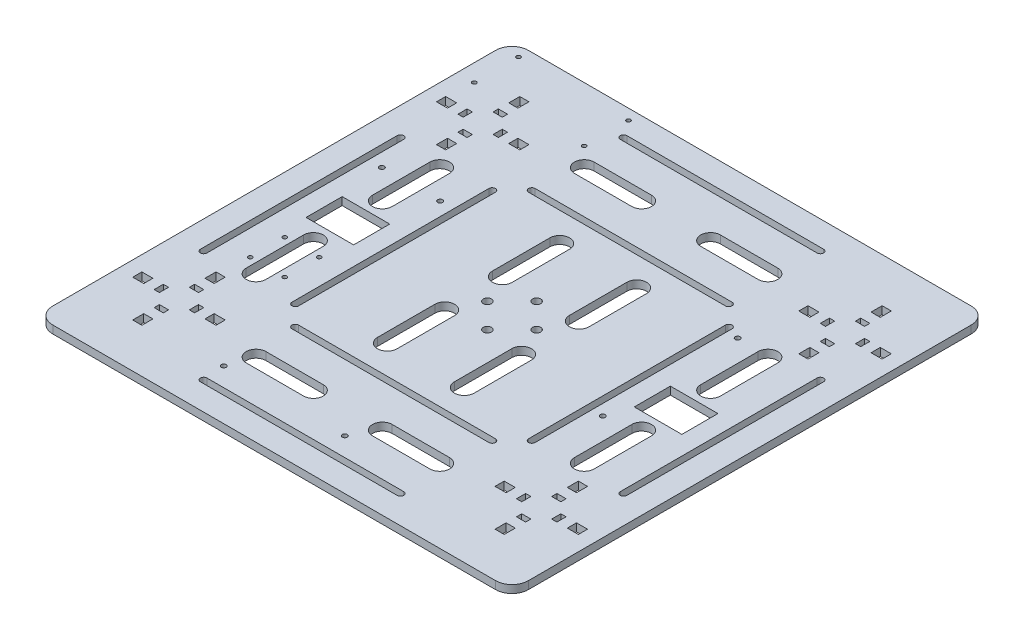
from build123d import *

# Parameters (mm, degrees)
SKETCH1_W                 = 290
SKETCH1_H                 = 290
BOSS_EXTRUDE1_DEPTH       = 4.7625
FILLET1_R                 = 10
SKETCH3_W                 = 5.588
SKETCH3_H                 = 6.731
SKETCH3_W_2               = 6.731
SKETCH3_H_2               = 5.588
SKETCH3_H_3               = 3.2
SKETCH3_W_3               = 3.2
CUT_EXTRUDE1_DEPTH        = 4.7625
MIRROR2_COPY_1_SKETCH_W   = 5.588
MIRROR2_COPY_1_SKETCH_H   = 6.731
MIRROR2_COPY_1_SKETCH_W_2 = 6.731
MIRROR2_COPY_1_SKETCH_H_2 = 5.588
MIRROR2_COPY_1_SKETCH_H_3 = 3.2
MIRROR2_COPY_1_SKETCH_W_3 = 3.2
MIRROR2_COPY_1_DEPTH      = 4.7625
CUT_EXTRUDE2_DEPTH        = 4.7625
SKETCH5_W                 = 29
SKETCH5_H                 = 22
CUT_EXTRUDE3_DEPTH        = 4.7625
CUT_EXTRUDE4_DEPTH        = 4.7625
SKETCH7_R                 = 2.5
CUT_EXTRUDE5_DEPTH        = 4.7625
SKETCH10_R                = 1.25
SKETCH10_R_2              = 1.5
CUT_EXTRUDE6_DEPTH        = 4.7625


with BuildPart() as part:
    # Sketch1 → Boss-Extrude1 (new body)
    with BuildSketch(Plane(origin=(0, 0, 0), x_dir=(1, 0, 0), z_dir=(0, 1, 0))):
        Rectangle(SKETCH1_W, SKETCH1_H)
    extrude(amount=BOSS_EXTRUDE1_DEPTH)

    # Fillet1
    fillet1_edges = [part.edges().sort_by_distance(p)[0] for p in [
        (-145, 2.38125, -145),
        (145, 2.38125, -145),
        (145, 2.38125, 145),
        (-145, 2.38125, 145),
    ]]
    fillet(fillet1_edges, radius=FILLET1_R)

    # Sketch3 → Cut-Extrude1 (cut)
    with BuildSketch(Plane(origin=(0, 4.7625, 0), x_dir=(1, 0, 0), z_dir=(0, 1, 0))):
        with Locations((-110.456, 114.6345)):
            Rectangle(SKETCH3_W, SKETCH3_H)
        with Locations((-88.4215, 92.6)):
            Rectangle(SKETCH3_W_2, SKETCH3_H_2)
        with Locations((-110.456, 70.5655)):
            Rectangle(SKETCH3_W, SKETCH3_H)
        with Locations((-132.4905, 92.6)):
            Rectangle(SKETCH3_W_2, SKETCH3_H_2)
        with Locations((-110.456, 103.325)):
            Rectangle(SKETCH3_W, SKETCH3_H_3)
        with Locations((-121.181, 92.6)):
            Rectangle(SKETCH3_W_3, SKETCH3_H_2)
        with Locations((-99.731, 92.6)):
            Rectangle(SKETCH3_W_3, SKETCH3_H_2)
        with Locations((-110.456, 81.875)):
            Rectangle(SKETCH3_W, SKETCH3_H_3)
    cut_extrude1 = extrude(amount=-CUT_EXTRUDE1_DEPTH, mode=Mode.SUBTRACT)

    # Mirror1: Cut-Extrude1 across plane
    add(cut_extrude1.mirror(Plane.XY), mode=Mode.SUBTRACT)

    # Mirror2: Cut-Extrude1 across plane
    add(cut_extrude1.mirror(Plane(origin=(0, 0, 0), x_dir=(0, 0, 1), z_dir=(1, 0, 0))), mode=Mode.SUBTRACT)

    # Mirror2 copy 1 sketch → Mirror2 copy 1 (cut)
    with BuildSketch(Plane(origin=(0, 4.7625, 0), x_dir=(-1, 0, 0), z_dir=(0, 1, 0))):
        with Locations((-110.456, 114.6345)):
            Rectangle(MIRROR2_COPY_1_SKETCH_W, MIRROR2_COPY_1_SKETCH_H)
        with Locations((-88.4215, 92.6)):
            Rectangle(MIRROR2_COPY_1_SKETCH_W_2, MIRROR2_COPY_1_SKETCH_H_2)
        with Locations((-110.456, 70.5655)):
            Rectangle(MIRROR2_COPY_1_SKETCH_W, MIRROR2_COPY_1_SKETCH_H)
        with Locations((-132.4905, 92.6)):
            Rectangle(MIRROR2_COPY_1_SKETCH_W_2, MIRROR2_COPY_1_SKETCH_H_2)
        with Locations((-110.456, 103.325)):
            Rectangle(MIRROR2_COPY_1_SKETCH_W, MIRROR2_COPY_1_SKETCH_H_3)
        with Locations((-121.181, 92.6)):
            Rectangle(MIRROR2_COPY_1_SKETCH_W_3, MIRROR2_COPY_1_SKETCH_H_2)
        with Locations((-99.731, 92.6)):
            Rectangle(MIRROR2_COPY_1_SKETCH_W_3, MIRROR2_COPY_1_SKETCH_H_2)
        with Locations((-110.456, 81.875)):
            Rectangle(MIRROR2_COPY_1_SKETCH_W, MIRROR2_COPY_1_SKETCH_H_3)
    extrude(amount=-MIRROR2_COPY_1_DEPTH, mode=Mode.SUBTRACT)

    # Sketch4 → Cut-Extrude2 (cut)
    with BuildSketch(Plane(origin=(0, 4.7625, 0), x_dir=(1, 0, 0), z_dir=(0, 1, 0))):
        with BuildLine():
            Line((-60, 130), (60, 130))
            ThreePointArc((60, 130), (62, 128), (60, 126))
            Line((60, 126), (-60, 126))
            ThreePointArc((-60, 126), (-62, 128), (-60, 130))
        make_face()
        with BuildLine():
            Line((-60, 74.12), (60, 74.12))
            ThreePointArc((60, 74.12), (62, 72.12), (60, 70.12))
            Line((60, 70.12), (-60, 70.12))
            ThreePointArc((-60, 70.12), (-62, 72.12), (-60, 74.12))
        make_face()
        with BuildLine():
            Line((130, 60), (130, -60))
            ThreePointArc((130, -60), (128, -62), (126, -60))
            Line((126, -60), (126, 60))
            ThreePointArc((126, 60), (128, 62), (130, 60))
        make_face()
        with BuildLine():
            Line((74.12, 60), (74.12, -60))
            ThreePointArc((74.12, -60), (72.12, -62), (70.12, -60))
            Line((70.12, -60), (70.12, 60))
            ThreePointArc((70.12, 60), (72.12, 62), (74.12, 60))
        make_face()
        with BuildLine():
            Line((60, -130), (-60, -130))
            ThreePointArc((-60, -130), (-62, -128), (-60, -126))
            Line((-60, -126), (60, -126))
            ThreePointArc((60, -126), (62, -128), (60, -130))
        make_face()
        with BuildLine():
            Line((60, -74.12), (-60, -74.12))
            ThreePointArc((-60, -74.12), (-62, -72.12), (-60, -70.12))
            Line((-60, -70.12), (60, -70.12))
            ThreePointArc((60, -70.12), (62, -72.12), (60, -74.12))
        make_face()
        with BuildLine():
            Line((-130, -60), (-130, 60))
            ThreePointArc((-130, 60), (-128, 62), (-126, 60))
            Line((-126, 60), (-126, -60))
            ThreePointArc((-126, -60), (-128, -62), (-130, -60))
        make_face()
        with BuildLine():
            Line((-74.12, -60), (-74.12, 60))
            ThreePointArc((-74.12, 60), (-72.12, 62), (-70.12, 60))
            Line((-70.12, 60), (-70.12, -60))
            ThreePointArc((-70.12, -60), (-72.12, -62), (-74.12, -60))
        make_face()
    extrude(amount=-CUT_EXTRUDE2_DEPTH, mode=Mode.SUBTRACT)

    # Sketch5 → Cut-Extrude3 (cut)
    with BuildSketch(Plane(origin=(0, 4.7625, 0), x_dir=(1, 0, 0), z_dir=(0, 1, 0))):
        with Locations((-100.06, 0)):
            Rectangle(SKETCH5_W, SKETCH5_H)
        with Locations((100.06, 0)):
            Rectangle(SKETCH5_W, SKETCH5_H)
    extrude(amount=-CUT_EXTRUDE3_DEPTH, mode=Mode.SUBTRACT)

    # Sketch6 → Cut-Extrude4 (cut)
    with BuildSketch(Plane(origin=(0, 4.7625, 0), x_dir=(1, 0, 0), z_dir=(0, 1, 0))):
        with BuildLine():
            Line((-56, 106.06), (-21, 106.06))
            ThreePointArc((-21, 106.06), (-15, 100.06), (-21, 94.06))
            Line((-21, 94.06), (-56, 94.06))
            ThreePointArc((-56, 94.06), (-62, 100.06), (-56, 106.06))
        make_face()
        with BuildLine():
            Line((21, 106.06), (56, 106.06))
            ThreePointArc((56, 106.06), (62, 100.06), (56, 94.06))
            Line((56, 94.06), (21, 94.06))
            ThreePointArc((21, 94.06), (15, 100.06), (21, 106.06))
        make_face()
        with BuildLine():
            Line((94.06, 56), (94.06, 21))
            ThreePointArc((94.06, 21), (100.06, 15), (106.06, 21))
            Line((106.06, 21), (106.06, 56))
            ThreePointArc((106.06, 56), (100.06, 62), (94.06, 56))
        make_face()
        with BuildLine():
            Line((94.06, -21), (94.06, -56))
            ThreePointArc((94.06, -56), (100.06, -62), (106.06, -56))
            Line((106.06, -56), (106.06, -21))
            ThreePointArc((106.06, -21), (100.06, -15), (94.06, -21))
        make_face()
        with BuildLine():
            Line((56, -94.06), (21, -94.06))
            ThreePointArc((21, -94.06), (15, -100.06), (21, -106.06))
            Line((21, -106.06), (56, -106.06))
            ThreePointArc((56, -106.06), (62, -100.06), (56, -94.06))
        make_face()
        with BuildLine():
            Line((-21, -94.06), (-56, -94.06))
            ThreePointArc((-56, -94.06), (-62, -100.06), (-56, -106.06))
            Line((-56, -106.06), (-21, -106.06))
            ThreePointArc((-21, -106.06), (-15, -100.06), (-21, -94.06))
        make_face()
        with BuildLine():
            Line((-94.06, -56), (-94.06, -21))
            ThreePointArc((-94.06, -21), (-100.06, -15), (-106.06, -21))
            Line((-106.06, -21), (-106.06, -56))
            ThreePointArc((-106.06, -56), (-100.06, -62), (-94.06, -56))
        make_face()
        with BuildLine():
            Line((-94.06, 21), (-94.06, 56))
            ThreePointArc((-94.06, 56), (-100.06, 62), (-106.06, 56))
            Line((-106.06, 56), (-106.06, 21))
            ThreePointArc((-106.06, 21), (-100.06, 15), (-94.06, 21))
        make_face()
        with BuildLine():
            Line((-17.453333333, 52.56), (-17.453333333, 17.56))
            ThreePointArc((-17.453333333, 17.56), (-23.453333333, 11.56), (-29.453333333, 17.56))
            Line((-29.453333333, 17.56), (-29.453333333, 52.56))
            ThreePointArc((-29.453333333, 52.56), (-23.453333333, 58.56), (-17.453333333, 52.56))
        make_face()
        with BuildLine():
            Line((17.453333333, 52.56), (17.453333333, 17.56))
            ThreePointArc((17.453333333, 17.56), (23.453333333, 11.56), (29.453333333, 17.56))
            Line((29.453333333, 17.56), (29.453333333, 52.56))
            ThreePointArc((29.453333333, 52.56), (23.453333333, 58.56), (17.453333333, 52.56))
        make_face()
        with BuildLine():
            Line((-17.453333333, -52.56), (-17.453333333, -17.56))
            ThreePointArc((-17.453333333, -17.56), (-23.453333333, -11.56), (-29.453333333, -17.56))
            Line((-29.453333333, -17.56), (-29.453333333, -52.56))
            ThreePointArc((-29.453333333, -52.56), (-23.453333333, -58.56), (-17.453333333, -52.56))
        make_face()
        with BuildLine():
            Line((17.453333333, -52.56), (17.453333333, -17.56))
            ThreePointArc((17.453333333, -17.56), (23.453333333, -11.56), (29.453333333, -17.56))
            Line((29.453333333, -17.56), (29.453333333, -52.56))
            ThreePointArc((29.453333333, -52.56), (23.453333333, -58.56), (17.453333333, -52.56))
        make_face()
    extrude(amount=-CUT_EXTRUDE4_DEPTH, mode=Mode.SUBTRACT)

    # Sketch7 → Cut-Extrude5 (cut)
    with BuildSketch(Plane(origin=(0, 4.7625, 0), x_dir=(1, 0, 0), z_dir=(0, 1, 0))):
        with Locations((0, 15)):
            Circle(SKETCH7_R)
        with Locations((15, 0)):
            Circle(SKETCH7_R)
        with Locations((0, -15)):
            Circle(SKETCH7_R)
        with Locations((-15, 0)):
            Circle(SKETCH7_R)
    extrude(amount=-CUT_EXTRUDE5_DEPTH, mode=Mode.SUBTRACT)

    # Sketch10 → Cut-Extrude6 (cut)
    with BuildSketch(Plane(origin=(0, 4.7625, 0), x_dir=(1, 0, 0), z_dir=(0, 1, 0))):
        with Locations((-134.5, 138.5)):
            Circle(SKETCH10_R)
        with Locations((-134.5, 111.5)):
            Circle(SKETCH10_R)
        with Locations((-67.5, 111.5)):
            Circle(SKETCH10_R)
        with Locations((-67.5, 138.5)):
            Circle(SKETCH10_R)
        with Locations((-82.31, 38.5)):
            Circle(SKETCH10_R_2)
        with Locations((-117.81, 38.5)):
            Circle(SKETCH10_R_2)
        with Locations((-110.56, -28)):
            Circle(SKETCH10_R)
        with Locations((-110.56, -49)):
            Circle(SKETCH10_R)
        with Locations((-89.56, -28)):
            Circle(SKETCH10_R)
        with Locations((-89.56, -49)):
            Circle(SKETCH10_R)
        with Locations((-61.25, -114.5)):
            Circle(SKETCH10_R_2)
        with Locations((12.55, -114.5)):
            Circle(SKETCH10_R_2)
        with Locations((80.756, 56.832204604)):
            Circle(SKETCH10_R_2)
        with Locations((80.756, -25.414883186)):
            Circle(SKETCH10_R_2)
    extrude(amount=-CUT_EXTRUDE6_DEPTH, mode=Mode.SUBTRACT)


solid = part.part
